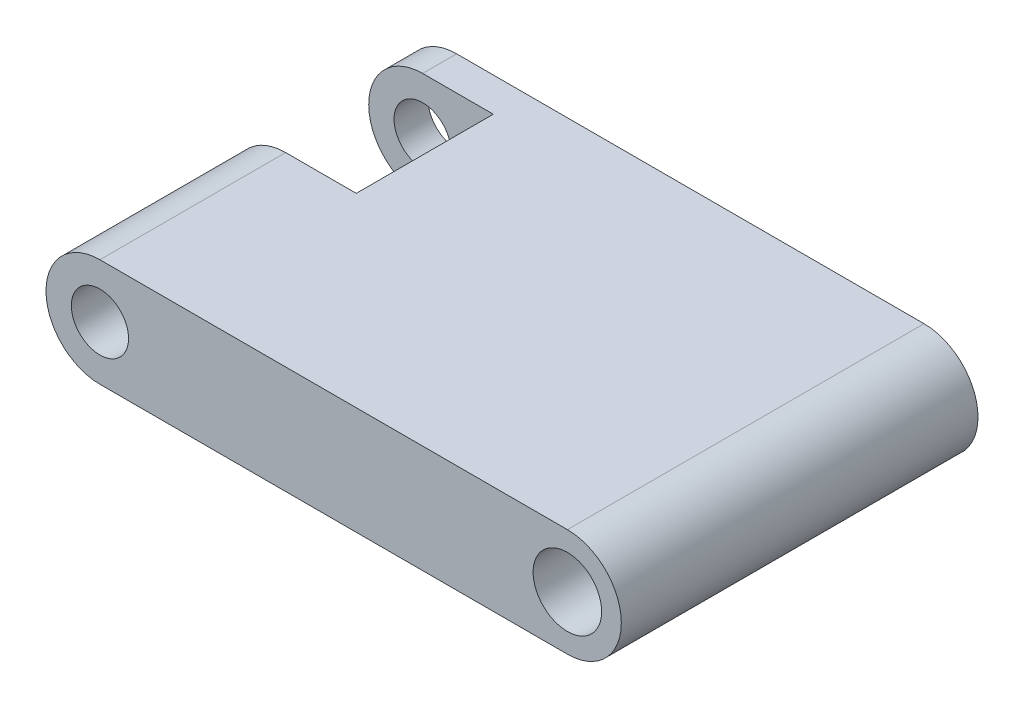
from build123d import *

# Parameters (mm, degrees)
SKETCH5_R           = 2.525
SKETCH5_R_2         = 3.025
BOSS_EXTRUDE2_DEPTH = 15.748
SKETCH6_W           = 11
SKETCH6_H           = 12.1
CUT_EXTRUDE2_DEPTH  = 12.7


with BuildPart() as part:
    # Sketch5 → Boss-Extrude2 (new body, symmetric)
    with BuildSketch(Plane.XY):
        with BuildLine():
            Line((-20.6375, 4.7625), (20.6375, 4.7625))
            ThreePointArc((20.6375, 4.7625), (25.4, 0), (20.6375, -4.7625))
            Line((20.6375, -4.7625), (-20.6375, -4.7625))
            ThreePointArc((-20.6375, -4.7625), (-25.4, 0), (-20.6375, 4.7625))
        make_face()
        with Locations((-20.6375, 0)):
            Circle(SKETCH5_R, mode=Mode.SUBTRACT)
        with Locations((20.6375, 0)):
            Circle(SKETCH5_R_2, mode=Mode.SUBTRACT)
    extrude(amount=BOSS_EXTRUDE2_DEPTH, both=True)

    # Sketch6 → Cut-Extrude2 (cut, symmetric)
    with BuildSketch(Plane(origin=(0, 0, 0), x_dir=(1, 0, 0), z_dir=(0, 1, 0))):
        with Locations((-19.9, 6.698)):
            Rectangle(SKETCH6_W, SKETCH6_H)
    extrude(amount=CUT_EXTRUDE2_DEPTH, both=True, mode=Mode.SUBTRACT)


solid = part.part
